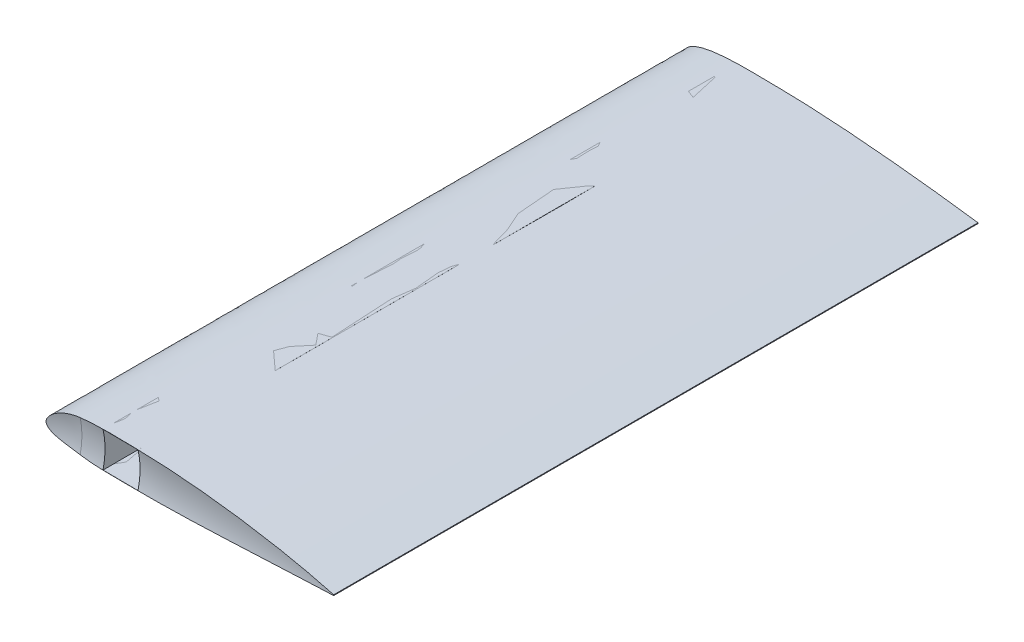
from build123d import *

# Parameters (mm, degrees)
SKETCH5_W          = 19.05
SKETCH5_H          = 19.05
CUT_EXTRUDE1_DEPTH = 382.0000001


with BuildPart() as part:
    # Sketch3 → Loft1 section 0
    with BuildSketch(Plane.XY):
        with BuildLine():
            Line((158.75, 0.200025), (158.75, -0.200025))
            add(Edge.make_bspline(
                [(158.75, 0.200025), (156.104769639, 0.564899501), (150.817056987, 1.294269442), (142.878358215, 2.306719234), (134.940769513, 3.268408227), (127.002836924, 4.172206586), (119.065195908, 5.02492376), (111.127662782, 5.825402282), (103.190287717, 6.571495389), (95.252619427, 7.253962327), (87.315238521, 7.873917198), (79.324754405, 8.420599463), (71.334509538, 8.88842609), (63.343416227, 9.23480821), (55.405395055, 9.490745127), (48.841491744, 9.486272029), (43.603543006, 9.608252324), (39.687659066, 9.662780631), (35.718784429, 9.691452396), (31.749587034, 9.673907615), (27.779893882, 9.591546914), (23.80909263, 9.423916942), (19.83652587, 9.137555224), (16.126941466, 8.724596023), (12.680513312, 8.159487318), (10.032530426, 7.556873589), (7.922127502, 6.918815912), (6.324809311, 6.335015586), (4.718104282, 5.602959138), (3.08294517, 4.643752576), (1.726538443, 3.521961778), (0.531933312, 2.020395179), (-0.347353812, 0), (0.531933312, -2.020395179), (1.726538443, -3.521961778), (3.08294517, -4.643752576), (4.718104282, -5.602959138), (6.324809311, -6.335015586), (7.922127502, -6.918815912), (10.032530426, -7.556873589), (12.680513312, -8.159487318), (16.126941466, -8.724596023), (19.83652587, -9.137555224), (23.80909263, -9.423916942), (27.779893882, -9.591546914), (31.749587034, -9.673907615), (35.718784429, -9.691452396), (39.687659066, -9.662780631), (43.603543006, -9.608252324), (48.841491744, -9.486272029), (55.405395055, -9.490745127), (63.343416227, -9.23480821), (71.334509538, -8.88842609), (79.324754405, -8.420599463), (87.315238521, -7.873917198), (95.252619427, -7.253962327), (103.190287717, -6.571495389), (111.127662782, -5.825402282), (119.065195908, -5.02492376), (127.002836924, -4.172206586), (134.940769513, -3.268408227), (142.878358215, -2.306719234), (150.817056987, -1.294269442), (156.104769639, -0.564899501), (158.75, -0.200025)],
                knots=[0, 0, 0, 0, 0.024634231, 0.04924287, 0.07382978, 0.098396751, 0.122945996, 0.147478562, 0.171994581, 0.196493552, 0.220976186, 0.245442093, 0.270380478, 0.294812969, 0.319231823, 0.343641967, 0.355360378, 0.36756608, 0.379770767, 0.391975369, 0.404182653, 0.416398684, 0.428636132, 0.440920171, 0.450818129, 0.460843203, 0.465945571, 0.471149096, 0.476522598, 0.482208155, 0.488618357, 0.492567758, 0.5, 0.507432242, 0.511381643, 0.517791845, 0.523477402, 0.528850904, 0.534054429, 0.539156797, 0.549181871, 0.559079829, 0.571363868, 0.583601316, 0.595817347, 0.608024631, 0.620229233, 0.63243392, 0.644639622, 0.656358033, 0.680768177, 0.705187031, 0.729619522, 0.754557907, 0.779023814, 0.803506448, 0.828005419, 0.852521438, 0.877054004, 0.901603249, 0.92617022, 0.95075713, 0.975365769, 1, 1, 1, 1], degree=3))
        make_face()
    # Sketch4 → Loft1 section 1
    with BuildSketch(Plane.XY.offset(381)):
        with BuildLine():
            Line((158.75, 0.200025), (158.75, -0.200025))
            add(Edge.make_bspline(
                [(158.75, 0.200025), (156.104769639, 0.564899501), (150.817056987, 1.294269442), (142.878358215, 2.306719234), (134.940769513, 3.268408227), (127.002836924, 4.172206586), (119.065195908, 5.02492376), (111.127662782, 5.825402282), (103.190287717, 6.571495389), (95.252619427, 7.253962327), (87.315238521, 7.873917198), (79.324754405, 8.420599463), (71.334509538, 8.88842609), (63.343416227, 9.23480821), (55.405395055, 9.490745127), (48.841491744, 9.486272029), (43.603543006, 9.608252324), (39.687659066, 9.662780631), (35.718784429, 9.691452396), (31.749587034, 9.673907615), (27.779893882, 9.591546914), (23.80909263, 9.423916942), (19.83652587, 9.137555224), (16.126941466, 8.724596023), (12.680513312, 8.159487318), (10.032530426, 7.556873589), (7.922127502, 6.918815912), (6.324809311, 6.335015586), (4.718104282, 5.602959138), (3.08294517, 4.643752576), (1.726538443, 3.521961778), (0.531933312, 2.020395179), (-0.347353812, 0), (0.531933312, -2.020395179), (1.726538443, -3.521961778), (3.08294517, -4.643752576), (4.718104282, -5.602959138), (6.324809311, -6.335015586), (7.922127502, -6.918815912), (10.032530426, -7.556873589), (12.680513312, -8.159487318), (16.126941466, -8.724596023), (19.83652587, -9.137555224), (23.80909263, -9.423916942), (27.779893882, -9.591546914), (31.749587034, -9.673907615), (35.718784429, -9.691452396), (39.687659066, -9.662780631), (43.603543006, -9.608252324), (48.841491744, -9.486272029), (55.405395055, -9.490745127), (63.343416227, -9.23480821), (71.334509538, -8.88842609), (79.324754405, -8.420599463), (87.315238521, -7.873917198), (95.252619427, -7.253962327), (103.190287717, -6.571495389), (111.127662782, -5.825402282), (119.065195908, -5.02492376), (127.002836924, -4.172206586), (134.940769513, -3.268408227), (142.878358215, -2.306719234), (150.817056987, -1.294269442), (156.104769639, -0.564899501), (158.75, -0.200025)],
                knots=[0, 0, 0, 0, 0.024634231, 0.04924287, 0.07382978, 0.098396751, 0.122945996, 0.147478562, 0.171994581, 0.196493552, 0.220976186, 0.245442093, 0.270380478, 0.294812969, 0.319231823, 0.343641967, 0.355360378, 0.36756608, 0.379770767, 0.391975369, 0.404182653, 0.416398684, 0.428636132, 0.440920171, 0.450818129, 0.460843203, 0.465945571, 0.471149096, 0.476522598, 0.482208155, 0.488618357, 0.492567758, 0.5, 0.507432242, 0.511381643, 0.517791845, 0.523477402, 0.528850904, 0.534054429, 0.539156797, 0.549181871, 0.559079829, 0.571363868, 0.583601316, 0.595817347, 0.608024631, 0.620229233, 0.63243392, 0.644639622, 0.656358033, 0.680768177, 0.705187031, 0.729619522, 0.754557907, 0.779023814, 0.803506448, 0.828005419, 0.852521438, 0.877054004, 0.901603249, 0.92617022, 0.95075713, 0.975365769, 1, 1, 1, 1], degree=3))
        make_face()
    loft()

    # Sketch5 → Cut-Extrude1 (cut, through all)
    with BuildSketch(Plane(origin=(0, 0, 0), x_dir=(-1, 0, 0), z_dir=(0, 0, -1))):
        with Locations((-38.1, 0)):
            Rectangle(SKETCH5_W, SKETCH5_H)
    extrude(amount=-CUT_EXTRUDE1_DEPTH, mode=Mode.SUBTRACT)

    # Sketch7 → Cut-Revolve1 (revolve, cut)
    with BuildSketch(Plane(origin=(0, 0, 0), x_dir=(1, 0, 0), z_dir=(0, 1, 0))):
        with BuildLine():
            Line((348.869, -382.27), (-25.4635, -382.27))
            ThreePointArc((-25.4635, -382.27), (-13.281338797, -411.680338797), (16.129, -423.8625))
            ThreePointArc((16.129, -423.8625), (183.883936795, -414.145744362), (348.869, -382.27))
        make_face()
    revolve(axis=Axis((348.869, 0, 382.27), (-1, 0, 0)), mode=Mode.SUBTRACT)


solid = part.part
